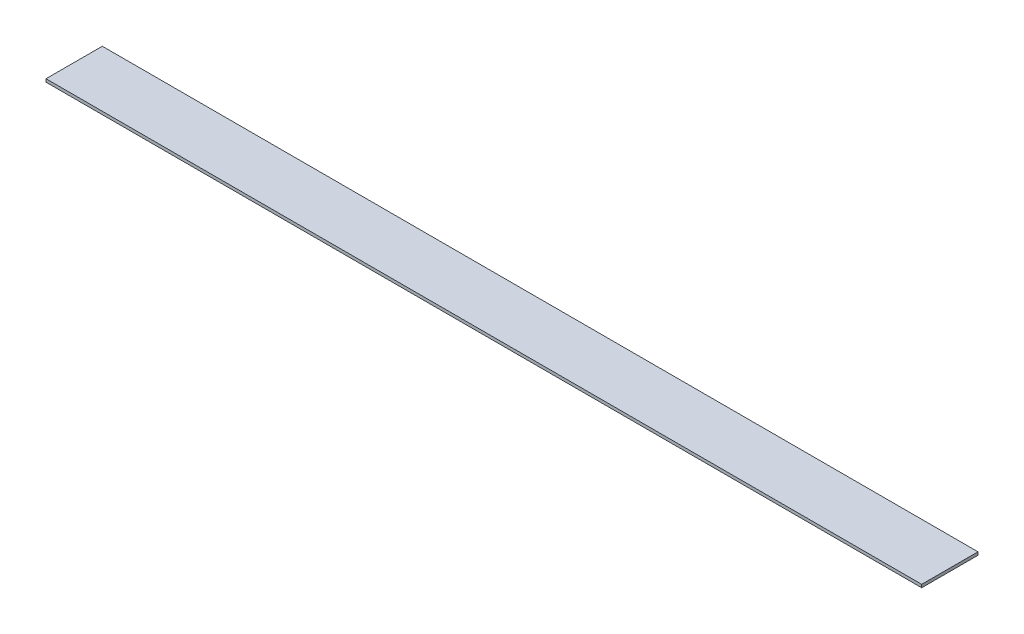
from build123d import *

# Parameters (mm, degrees)
SKETCH1_W           = 923.925
SKETCH1_H           = 59.4
BOSS_EXTRUDE1_DEPTH = 3.175


with BuildPart() as part:
    # Sketch1 → Boss-Extrude1 (new body)
    with BuildSketch(Plane(origin=(0, 0, 0), x_dir=(1, 0, 0), z_dir=(0, 1, 0))):
        with Locations((461.9625, 29.7)):
            Rectangle(SKETCH1_W, SKETCH1_H)
    extrude(amount=BOSS_EXTRUDE1_DEPTH)


solid = part.part
